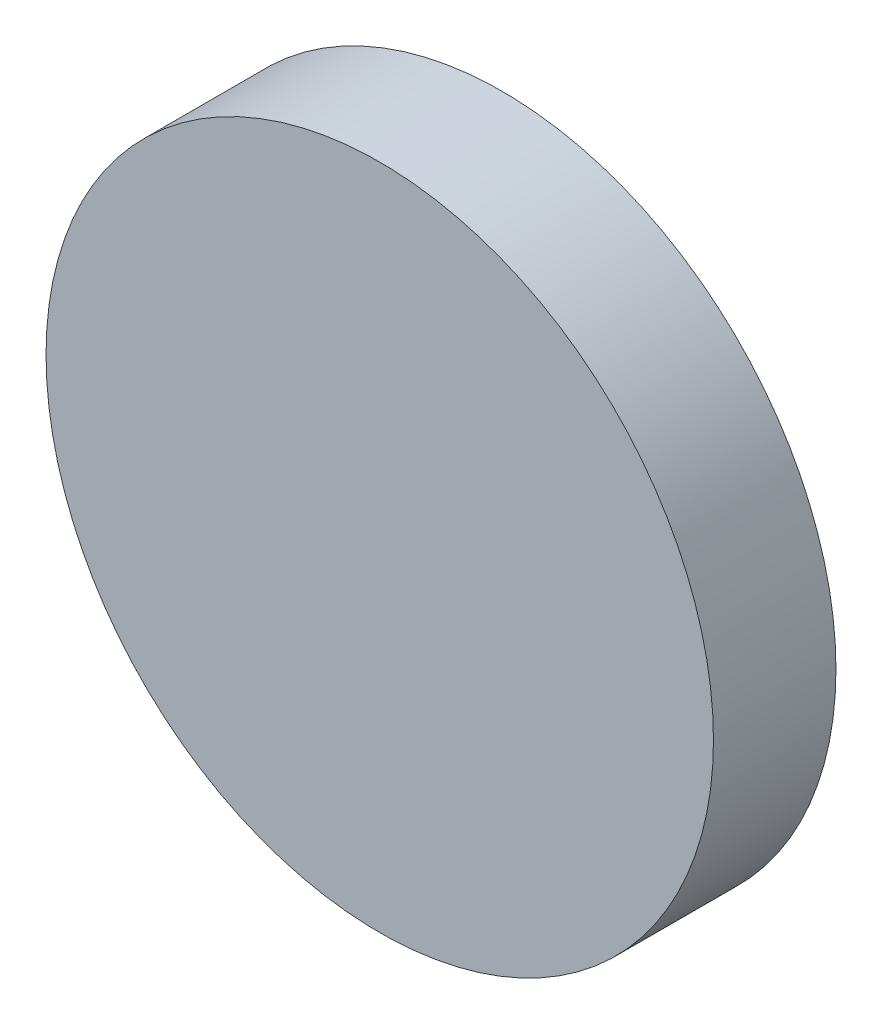
from build123d import *

# Parameters (mm, degrees)
SKETCH1_R           = 133.5
BOSS_EXTRUDE1_DEPTH = 49


with BuildPart() as part:
    # Sketch1 → Boss-Extrude1 (new body)
    with BuildSketch(Plane.XY):
        Circle(SKETCH1_R)
    extrude(amount=BOSS_EXTRUDE1_DEPTH)


solid = part.part
